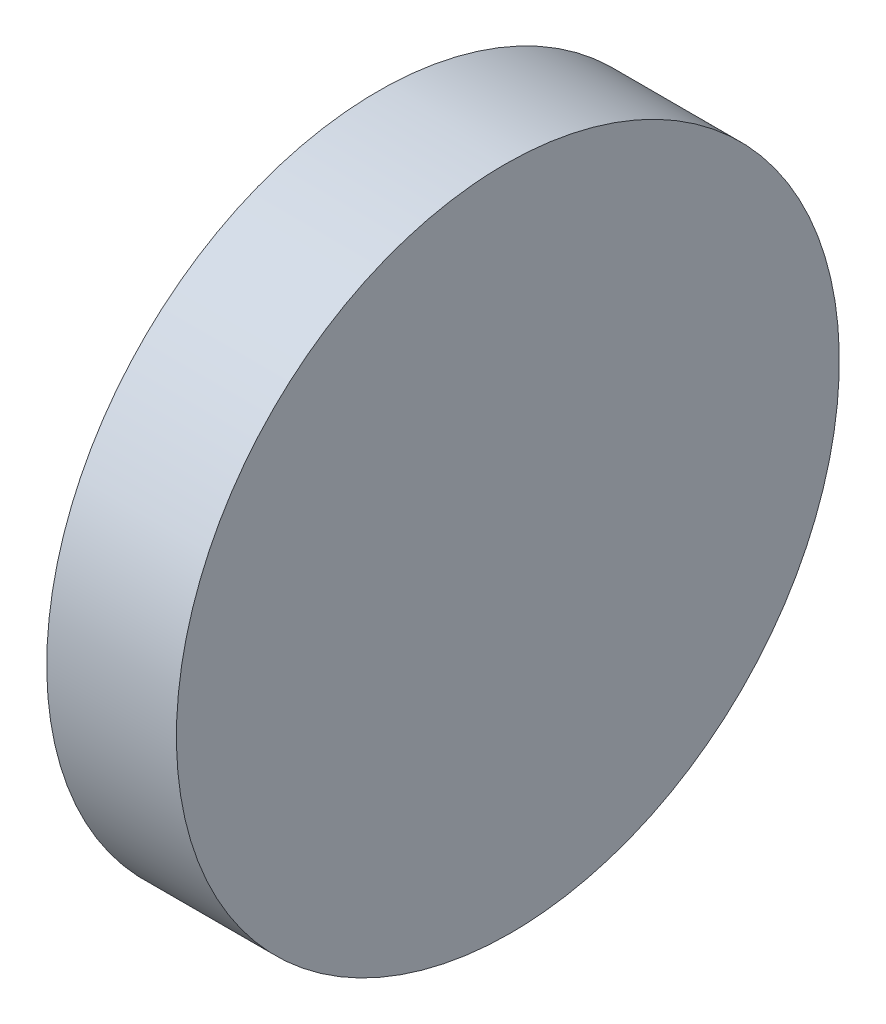
from build123d import *

# Parameters (mm, degrees)
EXTRUDE_1_DEPTH     = 50
CUT_EXTRUDE_1_DEPTH = 10


with BuildPart() as part:
    # 草图1 → 凸台-拉伸1 (new body)
    with BuildSketch(Plane.XY):
        Polygon((0, 25), (0, -25), (10, -25), (9.56365661, 25), align=None)
    extrude(amount=EXTRUDE_1_DEPTH)

    # 草图2 → 切除-拉伸1 (cut)
    with BuildSketch(Plane.ZY):
        with BuildLine():
            ThreePointArc((25, -25), (7.32233048, -17.677669539), (0, -2.6e-08))
            Line((0, -2.6e-08), (0, -25))
            Line((0, -25), (25, -25))
        make_face()
        with BuildLine():
            ThreePointArc((50, 0), (42.67766953, -17.67766953), (25, -25))
            Line((25, -25), (50, -25))
            Line((50, -25), (50, 0))
        make_face()
        with BuildLine():
            Line((50, 25), (25, 25))
            ThreePointArc((25, 25), (42.67766953, 17.67766953), (50, 0))
            Line((50, 0), (50, 25))
        make_face()
        with BuildLine():
            Line((25, 25), (0, 25))
            Line((0, 25), (0, -2.6e-08))
            ThreePointArc((0, -2.6e-08), (7.322330461, 17.67766952), (25, 25))
        make_face()
    extrude(amount=-CUT_EXTRUDE_1_DEPTH, mode=Mode.SUBTRACT)


solid = part.part
